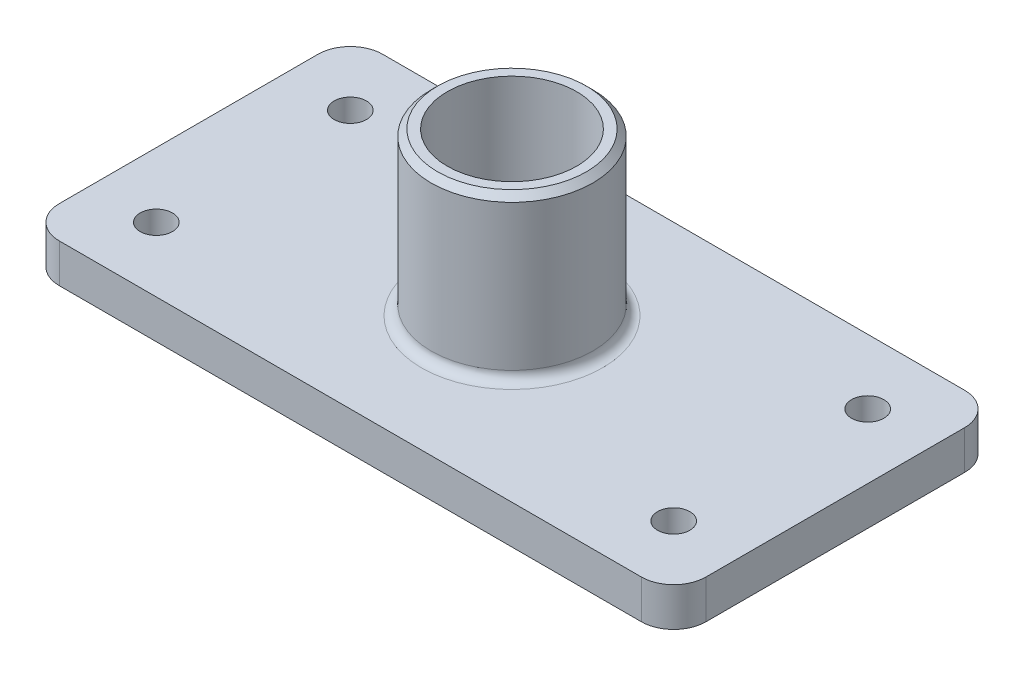
from build123d import *

# Parameters (mm, degrees)
SKETCH1_R           = 5
BOSS_EXTRUDE1_DEPTH = 12
SKETCH2_R           = 25
BOSS_EXTRUDE2_DEPTH = 50
SKETCH3_R           = 20
CUT_EXTRUDE1_DEPTH  = 63
FILLET1_R           = 3
CHAMFER1_SIZE       = 2


with BuildPart() as part:
    # Sketch1 → Boss-Extrude1 (new body)
    with BuildSketch(Plane(origin=(0, 0, 0), x_dir=(1, 0, 0), z_dir=(0, 1, 0))):
        with BuildLine():
            Line((-90, -50), (90, -50))
            ThreePointArc((90, -50), (97.071067812, -47.071067812), (100, -40))
            Line((100, -40), (100, 40))
            ThreePointArc((100, 40), (97.071067812, 47.071067812), (90, 50))
            Line((90, 50), (-90, 50))
            ThreePointArc((-90, 50), (-97.071067812, 47.071067812), (-100, 40))
            Line((-100, 40), (-100, -40))
            ThreePointArc((-100, -40), (-97.071067812, -47.071067812), (-90, -50))
        make_face()
        with Locations((-80, -30)):
            Circle(SKETCH1_R, mode=Mode.SUBTRACT)
        with Locations((-80, 30)):
            Circle(SKETCH1_R, mode=Mode.SUBTRACT)
        with Locations((80, 30)):
            Circle(SKETCH1_R, mode=Mode.SUBTRACT)
        with Locations((80, -30)):
            Circle(SKETCH1_R, mode=Mode.SUBTRACT)
    extrude(amount=BOSS_EXTRUDE1_DEPTH)

    # Sketch2 → Boss-Extrude2 (add)
    with BuildSketch(Plane(origin=(0, 12, 0), x_dir=(1, 0, 0), z_dir=(0, 1, 0))):
        Circle(SKETCH2_R)
    extrude(amount=BOSS_EXTRUDE2_DEPTH)

    # Sketch3 → Cut-Extrude1 (cut, through all)
    with BuildSketch(Plane(origin=(0, 62, 0), x_dir=(1, 0, 0), z_dir=(0, 1, 0))):
        Circle(SKETCH3_R)
    extrude(amount=-CUT_EXTRUDE1_DEPTH, mode=Mode.SUBTRACT)

    # Fillet1
    fillet1_edges = [part.edges().sort_by_distance(p)[0] for p in [
        (-25, 12, 0),
    ]]
    fillet(fillet1_edges, radius=FILLET1_R)

    # Chamfer1
    chamfer1_edges = [part.edges().sort_by_distance(p)[0] for p in [
        (-25, 62, 0),
    ]]
    chamfer(chamfer1_edges, length=CHAMFER1_SIZE)


solid = part.part
